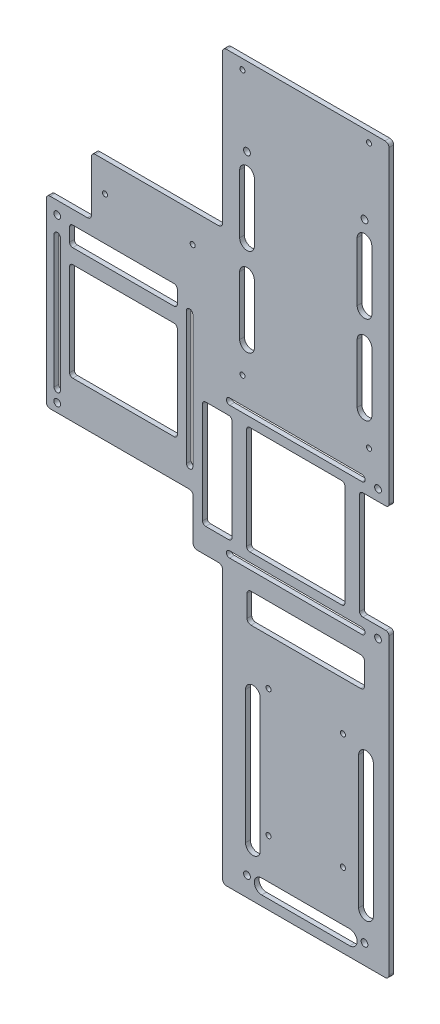
from build123d import *

# Parameters (mm, degrees)
SKETCH1_W                    = 107.95
SKETCH1_H                    = 469.9
BOSS_EXTRUDE1_DEPTH          = 3.0734
ARUDINO_WIRE_SLOTS_REACH     = 5.073
POWERBOARDWIREPASS_DEPTH     = 3.0734
LPATTERN2_COUNT              = 2
LPATTERN2_PITCH              = 57.15
LPATTERN2_COUNT_DIR2         = 2
LPATTERN2_PITCH_DIR2         = 76.2
SKETCH8_W                    = 76.2
SKETCH8_H                    = 19.05
CUT_EXTRUDE5_DEPTH           = 4.0734
F_30_0_1285_ARDUINO_MOUNTS_D = 3.2639
BOSS_EXTRUDE2_DEPTH          = 3.0734
F_30_0_1285_DIAMETER_HOLE1_D = 3.2639
CUT_EXTRUDE6_DEPTH           = 4.0734
FILLET1_R                    = 2.54
FILLET3_R                    = 2.54
SKETCH7_R                    = 2.1971
BRAIN_PANEL_MOUNTS_DEPTH     = 4.0734
SKETCH21_W                   = 29.21
SKETCH21_H                   = 38.1
CUT_EXTRUDE7_DEPTH           = 4.0734
FILLET2_R                    = 2.54


with BuildPart() as part:
    # Sketch1 → Boss-Extrude1 (new body)
    with BuildSketch(Plane.XY):
        with Locations((-105.516187574, 60.194877049)):
            Rectangle(SKETCH1_W, SKETCH1_H)
    extrude(amount=BOSS_EXTRUDE1_DEPTH)

    # Sketch2 → Arudino Wire Slots (cut, up to next)
    with BuildSketch(Plane.XY.offset(3.0734), mode=Mode.PRIVATE) as arudino_wire_slots_sk1:
        with BuildLine():
            Line((-134.091187574, -158.880122951), (-76.941187574, -158.880122951))
            ThreePointArc((-76.941187574, -158.880122951), (-72.178687574, -163.642622951), (-76.941187574, -168.405122951))
            Line((-76.941187574, -168.405122951), (-134.091187574, -168.405122951))
            ThreePointArc((-134.091187574, -168.405122951), (-138.853687574, -163.642622951), (-134.091187574, -158.880122951))
        make_face()
    arudino_wire_slots_tool1 = extrude(arudino_wire_slots_sk1.sketch, amount=-ARUDINO_WIRE_SLOTS_REACH, mode=Mode.PRIVATE) & part.part
    add(arudino_wire_slots_tool1.solids().sort_by_distance((-105.516188, -163.642623, 3.0734))[0], mode=Mode.SUBTRACT)
    # Sketch2 → Arudino Wire Slots (cut, up to next)
    with BuildSketch(Plane.XY.offset(3.0734), mode=Mode.PRIVATE) as arudino_wire_slots_sk2:
        with BuildLine():
            Line((-61.701187574, -58.259122951), (-61.701187574, -144.275122951))
            ThreePointArc((-61.701187574, -144.275122951), (-66.463687574, -149.037622951), (-71.226187574, -144.275122951))
            Line((-71.226187574, -144.275122951), (-71.226187574, -58.259122951))
            ThreePointArc((-71.226187574, -58.259122951), (-66.463687574, -53.496622951), (-61.701187574, -58.259122951))
        make_face()
    arudino_wire_slots_tool2 = extrude(arudino_wire_slots_sk2.sketch, amount=-ARUDINO_WIRE_SLOTS_REACH, mode=Mode.PRIVATE) & part.part
    add(arudino_wire_slots_tool2.solids().sort_by_distance((-66.463688, -101.267123, 3.0734))[0], mode=Mode.SUBTRACT)
    # Sketch2 → Arudino Wire Slots (cut, up to next)
    with BuildSketch(Plane.XY.offset(3.0734), mode=Mode.PRIVATE) as arudino_wire_slots_sk3:
        with BuildLine():
            Line((-144.568687574, -58.259122951), (-144.568687574, -144.275122951))
            ThreePointArc((-144.568687574, -144.275122951), (-139.806187574, -149.037622951), (-135.043687574, -144.275122951))
            Line((-135.043687574, -144.275122951), (-135.043687574, -58.259122951))
            ThreePointArc((-135.043687574, -58.259122951), (-139.806187574, -53.496622951), (-144.568687574, -58.259122951))
        make_face()
    arudino_wire_slots_tool3 = extrude(arudino_wire_slots_sk3.sketch, amount=-ARUDINO_WIRE_SLOTS_REACH, mode=Mode.PRIVATE) & part.part
    add(arudino_wire_slots_tool3.solids().sort_by_distance((-139.806188, -101.267123, 3.0734))[0], mode=Mode.SUBTRACT)

    # Sketch6 → PowerBoardWirePass (cut)
    with BuildSketch(Plane.XY.offset(3.0734)):
        with BuildLine():
            Line((-62.653687574, 231.644877049), (-62.653687574, 193.544877049))
            ThreePointArc((-62.653687574, 193.544877049), (-67.416187574, 188.782377049), (-72.178687574, 193.544877049))
            Line((-72.178687574, 193.544877049), (-72.178687574, 231.644877049))
            ThreePointArc((-72.178687574, 231.644877049), (-67.416187574, 236.407377049), (-62.653687574, 231.644877049))
        make_face()
    powerboardwirepass = extrude(amount=-POWERBOARDWIREPASS_DEPTH, mode=Mode.SUBTRACT)

    # LPattern2: PowerBoardWirePass 2 × 2
    with Locations(*[(-j * LPATTERN2_PITCH_DIR2, -i * LPATTERN2_PITCH, 0) for i in range(LPATTERN2_COUNT) for j in range(LPATTERN2_COUNT_DIR2) if (i, j) != (0, 0)]):
        add(powerboardwirepass, mode=Mode.SUBTRACT)

    # Sketch8 → Cut-Extrude5 (cut, through all)
    with BuildSketch(Plane.XY.offset(3.0734)):
        with Locations((-105.516187574, -10.830216602)):
            Rectangle(SKETCH8_W, SKETCH8_H)
    extrude(amount=-CUT_EXTRUDE5_DEPTH, mode=Mode.SUBTRACT)

    # #30 (0.1285) Arduino Mounts (through all)
    with Locations(Plane.XY.offset(3.0734)):
        with Locations((-129.646187574, -50.295122951), (-129.646187574, -132.845122951), (-81.386187574, -51.565122951), (-81.386187574, -126.495122951)):
            Hole(F_30_0_1285_ARDUINO_MOUNTS_D / 2)

    # Sketch18 → Boss-Extrude2 (add)
    with BuildSketch(Plane.XY):
        Polygon((-159.491187574, 193.544877049), (-273.791187574, 193.544877049), (-273.791187574, 36.064877049), (-178.541187574, 36.064877049), (-178.541187574, 4.314877049), (-159.491187574, 4.314877049), align=None)
    extrude(amount=BOSS_EXTRUDE2_DEPTH)

    # #30 (0.1285) Diameter Hole1 (through all)
    with Locations(Plane.XY.offset(3.0734)):
        with Locations((-64.495187574, 288.794877049), (-146.537187574, 288.794877049), (-146.537187574, 117.344877049), (-64.495187574, 117.344877049), (-235.691187574, 174.494877049), (-178.871387574, 174.494877049)):
            Hole(F_30_0_1285_DIAMETER_HOLE1_D / 2)

    # Sketch19 → Cut-Extrude6 (cut, through all)
    with BuildSketch(Plane.XY.offset(3.0734)):
        with BuildLine():
            Line((-153.395187574, 88.238577049), (-153.395187574, 22.488577049))
            ThreePointArc((-153.395187574, 22.488577049), (-153.995618672, 21.039008148), (-155.445187574, 20.438577049))
            Line((-155.445187574, 20.438577049), (-170.395187574, 20.438577049))
            ThreePointArc((-170.395187574, 20.438577049), (-171.844756475, 21.039008148), (-172.445187574, 22.488577049))
            Line((-172.445187574, 22.488577049), (-172.445187574, 88.238577049))
            ThreePointArc((-172.445187574, 88.238577049), (-171.844756475, 89.688145951), (-170.395187574, 90.288577049))
            Line((-170.395187574, 90.288577049), (-155.445187574, 90.288577049))
            ThreePointArc((-155.445187574, 90.288577049), (-153.995618672, 89.688145951), (-153.395187574, 88.238577049))
        make_face()
        with BuildLine():
            Line((-256.640887574, 146.554877049), (-190.890887574, 146.554877049))
            ThreePointArc((-190.890887574, 146.554877049), (-189.441318672, 145.954445951), (-188.840887574, 144.504877049))
            Line((-188.840887574, 144.504877049), (-188.840887574, 135.904877049))
            ThreePointArc((-188.840887574, 135.904877049), (-189.441318672, 134.455308148), (-190.890887574, 133.854877049))
            Line((-190.890887574, 133.854877049), (-256.640887574, 133.854877049))
            ThreePointArc((-256.640887574, 133.854877049), (-258.090456475, 134.455308148), (-258.690887574, 135.904877049))
            Line((-258.690887574, 135.904877049), (-258.690887574, 144.504877049))
            ThreePointArc((-258.690887574, 144.504877049), (-258.090456475, 145.954445951), (-256.640887574, 146.554877049))
        make_face()
        with BuildLine():
            Line((-268.747187574, 49.526877049), (-268.747187574, 135.378877049))
            ThreePointArc((-268.747187574, 135.378877049), (-266.697187574, 137.428877049), (-264.647187574, 135.378877049))
            Line((-264.647187574, 135.378877049), (-264.647187574, 49.526877049))
            ThreePointArc((-264.647187574, 49.526877049), (-266.697187574, 47.476877049), (-268.747187574, 49.526877049))
        make_face()
        with BuildLine():
            Line((-154.919187574, 100.344877049), (-69.067187574, 100.344877049))
            ThreePointArc((-69.067187574, 100.344877049), (-67.017187574, 98.294877049), (-69.067187574, 96.244877049))
            Line((-69.067187574, 96.244877049), (-154.919187574, 96.244877049))
            ThreePointArc((-154.919187574, 96.244877049), (-156.969187574, 98.294877049), (-154.919187574, 100.344877049))
        make_face()
        with BuildLine():
            Line((-53.591187574, 90.288577049), (-68.541187574, 90.288577049))
            ThreePointArc((-68.541187574, 90.288577049), (-69.990756475, 89.688145951), (-70.591187574, 88.238577049))
            Line((-70.591187574, 88.238577049), (-70.591187574, 22.488577049))
            ThreePointArc((-70.591187574, 22.488577049), (-69.990756475, 21.039008148), (-68.541187574, 20.438577049))
            Line((-68.541187574, 20.438577049), (-53.591187574, 20.438577049))
            ThreePointArc((-53.591187574, 20.438577049), (-52.141618672, 19.838145951), (-51.541187574, 18.388577049))
            Line((-51.541187574, 18.388577049), (-51.541187574, 92.338577049))
            ThreePointArc((-51.541187574, 92.338577049), (-52.141618672, 90.889008148), (-53.591187574, 90.288577049))
        make_face()
        with BuildLine():
            Line((-154.919187574, 10.392877049), (-69.067187574, 10.392877049))
            ThreePointArc((-69.067187574, 10.392877049), (-67.017187574, 12.442877049), (-69.067187574, 14.492877049))
            Line((-69.067187574, 14.492877049), (-154.919187574, 14.492877049))
            ThreePointArc((-154.919187574, 14.492877049), (-156.969187574, 12.442877049), (-154.919187574, 10.392877049))
        make_face()
        with BuildLine():
            Line((-80.116187574, 88.238577049), (-80.116187574, 22.488577049))
            ThreePointArc((-80.116187574, 22.488577049), (-80.716618672, 21.039008148), (-82.166187574, 20.438577049))
            Line((-82.166187574, 20.438577049), (-141.820187574, 20.438577049))
            ThreePointArc((-141.820187574, 20.438577049), (-143.269756475, 21.039008148), (-143.870187574, 22.488577049))
            Line((-143.870187574, 22.488577049), (-143.870187574, 88.238577049))
            ThreePointArc((-143.870187574, 88.238577049), (-143.269756475, 89.688145951), (-141.820187574, 90.288577049))
            Line((-141.820187574, 90.288577049), (-82.166187574, 90.288577049))
            ThreePointArc((-82.166187574, 90.288577049), (-80.716618672, 89.688145951), (-80.116187574, 88.238577049))
        make_face()
        with BuildLine():
            Line((-178.795187574, 49.526877049), (-178.795187574, 135.378877049))
            ThreePointArc((-178.795187574, 135.378877049), (-180.845187574, 137.428877049), (-182.895187574, 135.378877049))
            Line((-182.895187574, 135.378877049), (-182.895187574, 49.526877049))
            ThreePointArc((-182.895187574, 49.526877049), (-180.845187574, 47.476877049), (-178.795187574, 49.526877049))
        make_face()
        with BuildLine():
            Line((-256.640887574, 124.329877049), (-190.890887574, 124.329877049))
            ThreePointArc((-190.890887574, 124.329877049), (-189.441318672, 123.729445951), (-188.840887574, 122.279877049))
            Line((-188.840887574, 122.279877049), (-188.840887574, 62.625877049))
            ThreePointArc((-188.840887574, 62.625877049), (-189.441318672, 61.176308148), (-190.890887574, 60.575877049))
            Line((-190.890887574, 60.575877049), (-256.640887574, 60.575877049))
            ThreePointArc((-256.640887574, 60.575877049), (-258.090456475, 61.176308148), (-258.690887574, 62.625877049))
            Line((-258.690887574, 62.625877049), (-258.690887574, 122.279877049))
            ThreePointArc((-258.690887574, 122.279877049), (-258.090456475, 123.729445951), (-256.640887574, 124.329877049))
        make_face()
    extrude(amount=-CUT_EXTRUDE6_DEPTH, mode=Mode.SUBTRACT)

    # Fillet1
    fillet1_edges = [part.edges().sort_by_distance(p)[0] for p in [
        (-67.416187574, -1.305216602, 1.5367),
        (-67.416187574, -20.355216602, 1.5367),
        (-143.616187574, -20.355216602, 1.5367),
        (-143.616187574, -1.305216602, 1.5367),
    ]]
    fillet(fillet1_edges, radius=FILLET1_R)

    # Fillet3
    fillet3_edges = [part.edges().sort_by_distance(p)[0] for p in [
        (-159.491187574, 4.314877049, 1.5367),
        (-159.491187574, 193.544877049, 1.5367),
        (-273.791187574, 36.064877049, 1.5367),
        (-178.541187574, 36.064877049, 1.5367),
        (-178.541187574, 4.314877049, 1.5367),
    ]]
    fillet(fillet3_edges, radius=FILLET3_R)

    # Sketch7 → Brain-Panel-Mounts (cut, through all)
    with BuildSketch(Plane.XY.offset(3.0734)):
        with Locations((-143.616187574, 244.344877049)):
            Circle(SKETCH7_R)
        with Locations((-67.416187574, 244.344877049)):
            Circle(SKETCH7_R)
        with Locations((-143.616187574, -162.055122951)):
            Circle(SKETCH7_R)
        with Locations((-67.416187574, -162.055122951)):
            Circle(SKETCH7_R)
        with Locations((-266.697187574, 147.189877049)):
            Circle(SKETCH7_R)
        with Locations((-266.697187574, 41.779877049)):
            Circle(SKETCH7_R)
        with Locations((-58.653187574, 97.400577049)):
            Circle(SKETCH7_R)
        with Locations((-58.653187574, 13.326577049)):
            Circle(SKETCH7_R)
    extrude(amount=-BRAIN_PANEL_MOUNTS_DEPTH, mode=Mode.SUBTRACT)

    # Sketch21 → Cut-Extrude7 (cut, through all)
    with BuildSketch(Plane.XY.offset(3.0734)):
        with Locations((-259.186187574, 174.494877049)):
            Rectangle(SKETCH21_W, SKETCH21_H)
    extrude(amount=-CUT_EXTRUDE7_DEPTH, mode=Mode.SUBTRACT)

    # Fillet2
    fillet2_edges = [part.edges().sort_by_distance(p)[0] for p in [
        (-244.581187574, 193.544877049, 1.5367),
        (-244.581187574, 155.444877049, 1.5367),
        (-273.791187574, 155.444877049, 1.5367),
        (-51.541187574, -174.755122951, 1.5367),
        (-159.491187574, -174.755122951, 1.5367),
        (-159.491187574, 295.144877049, 1.5367),
        (-51.541187574, 295.144877049, 1.5367),
    ]]
    fillet(fillet2_edges, radius=FILLET2_R)


solid = part.part
